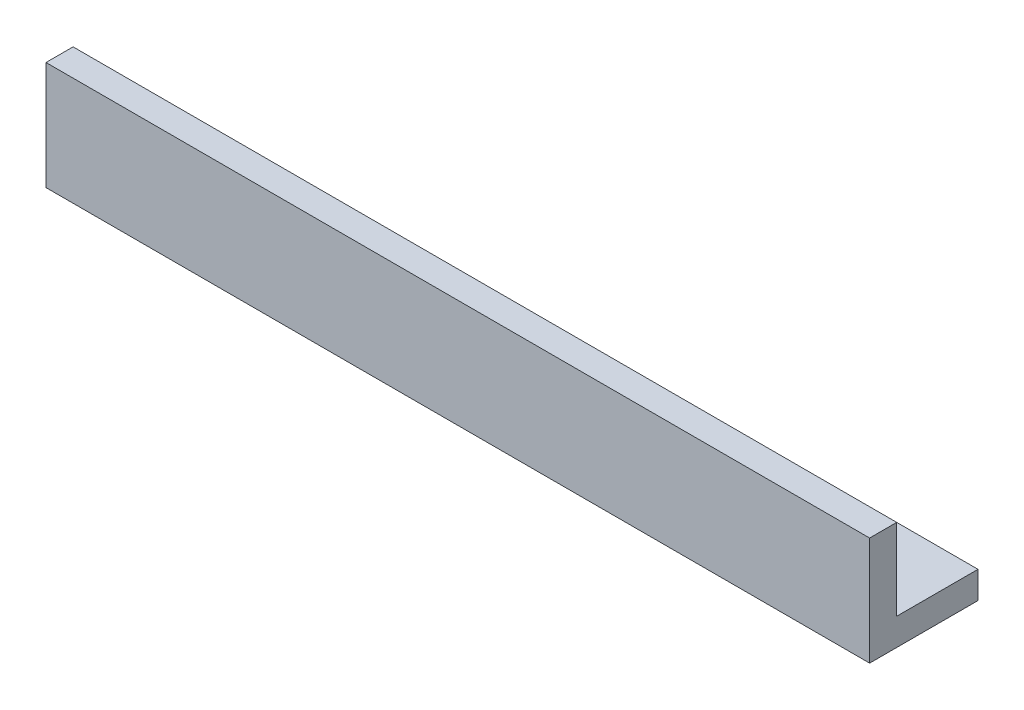
from build123d import *

# Parameters (mm, degrees)
SKETCH1_W           = 96.52
SKETCH1_H           = 12.7
BOSS_EXTRUDE1_DEPTH = 3.175
SKETCH7_W           = 96.52
SKETCH7_H           = 9.525
BOSS_EXTRUDE2_DEPTH = 3.175


with BuildPart() as part:
    # Sketch1 → Boss-Extrude1 (new body)
    with BuildSketch(Plane.XY):
        with Locations((23.526472643, 22.354273404)):
            Rectangle(SKETCH1_W, SKETCH1_H)
    extrude(amount=BOSS_EXTRUDE1_DEPTH)

    # Sketch7 → Boss-Extrude2 (add)
    with BuildSketch(Plane(origin=(0, 16.004273404, 0), x_dir=(-1, 0, 0), z_dir=(0, -1, 0))):
        with Locations((-23.526472643, 4.7625)):
            Rectangle(SKETCH7_W, SKETCH7_H)
    extrude(amount=-BOSS_EXTRUDE2_DEPTH)


solid = part.part
